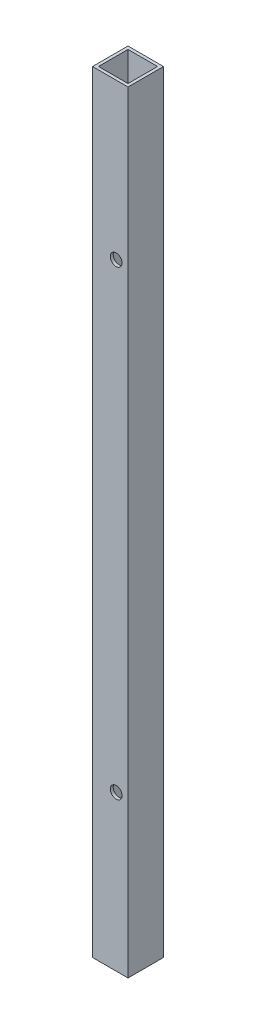
from build123d import *

# Parameters (mm, degrees)
SKETCH2_W           = 19.05
SKETCH2_H           = 19.05
SKETCH2_W_2         = 15.875
SKETCH2_H_2         = 15.875
BOSS_EXTRUDE1_DEPTH = 414.3375
SKETCH3_R           = 3.175
CUT_EXTRUDE1_DEPTH  = 20.05


with BuildPart() as part:
    # Sketch2 → Boss-Extrude1 (new body)
    with BuildSketch(Plane(origin=(0, 0, 0), x_dir=(1, 0, 0), z_dir=(0, 1, 0))):
        with Locations((9.525, 9.525)):
            Rectangle(SKETCH2_W, SKETCH2_H)
        with Locations((9.525, 9.525)):
            Rectangle(SKETCH2_W_2, SKETCH2_H_2, mode=Mode.SUBTRACT)
    extrude(amount=BOSS_EXTRUDE1_DEPTH)

    # Sketch3 → Cut-Extrude1 (cut, through all)
    with BuildSketch(Plane.XY):
        with Locations((12.7, 83.17992)):
            Circle(SKETCH3_R)
        with Locations((12.7, 330.82992)):
            Circle(SKETCH3_R)
    extrude(amount=-CUT_EXTRUDE1_DEPTH, mode=Mode.SUBTRACT)


solid = part.part
